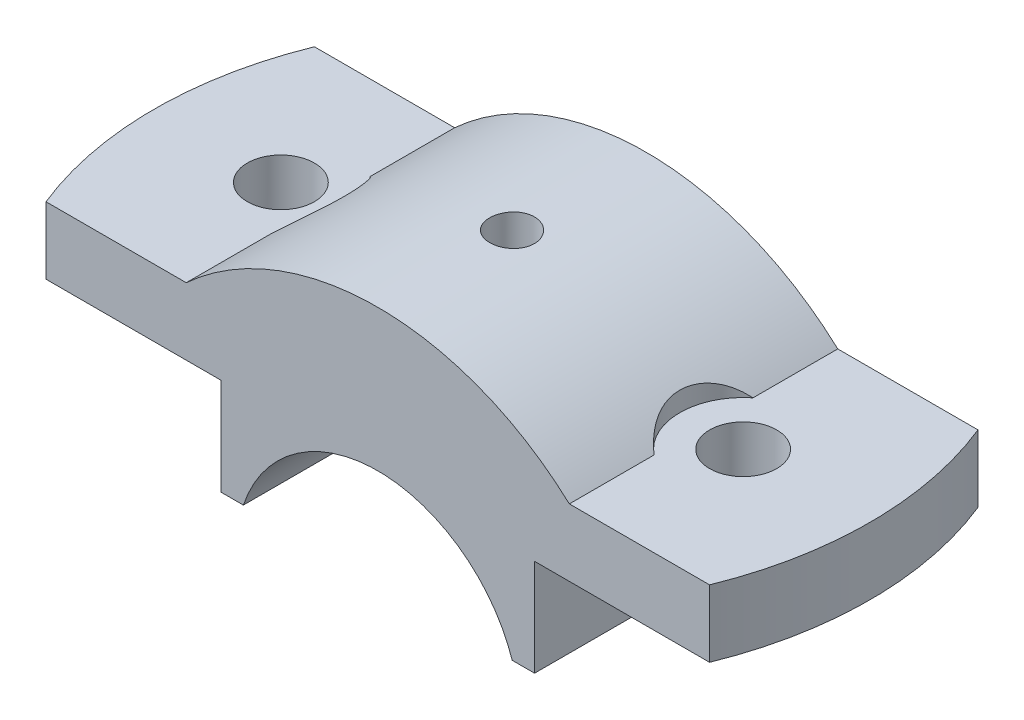
from build123d import *

# Parameters (mm, degrees)
BOSS_EXTRUDE2_DEPTH   = 18
F_6_0MM_DOWEL_HOLE4_D = 9
SKETCH16_R            = 8.5
CUT_EXTRUDE1_DEPTH    = 10
SKETCH17_R            = 8.5
CUT_EXTRUDE2_DEPTH    = 45
CUT_EXTRUDE3_DEPTH    = 23.0000001


with BuildPart() as part:
    # Sketch1 → Boss-Extrude2 (new body, symmetric)
    with BuildSketch(Plane.XY):
        with BuildLine():
            Line((18.027756377, 6), (21.027756377, 6))
            Line((21.027756377, 6), (21.027756377, 19))
            Line((21.027756377, 19), (50, 19))
            Line((50, 19), (50, 28))
            Line((50, 28), (25.690465157, 28))
            ThreePointArc((25.690465157, 28), (0, 38), (-25.690465157, 28))
            Line((-25.690465157, 28), (-50, 28))
            Line((-50, 28), (-50, 19))
            Line((-50, 19), (-21.027756377, 19))
            Line((-21.027756377, 19), (-21.027756377, 6))
            Line((-21.027756377, 6), (-18.027756377, 6))
            ThreePointArc((-18.027756377, 6), (0, 19), (18.027756377, 6))
        make_face()
    extrude(amount=BOSS_EXTRUDE2_DEPTH, both=True)

    # Ø6.0mm Dowel Hole4 (through all)
    with Locations(Plane(origin=(0, 28, 0), x_dir=(1, 0, 0), z_dir=(0, 1, 0))):
        with Locations((-31, 0)):
            f_6_0mm_dowel_hole4 = Hole(F_6_0MM_DOWEL_HOLE4_D / 2)

    # Mirror1: Ø6.0mm Dowel Hole4 across plane
    add(f_6_0mm_dowel_hole4.mirror(Plane(origin=(0, 0, 0), x_dir=(0, 0, 1), z_dir=(1, 0, 0))), mode=Mode.SUBTRACT)

    # Sketch16 → Cut-Extrude1 (cut)
    with BuildSketch(Plane(origin=(0, 38, 0), x_dir=(1, 0, 0), z_dir=(0, 1, 0))):
        with Locations((-31, 0)):
            Circle(SKETCH16_R)
    extrude(amount=-CUT_EXTRUDE1_DEPTH, mode=Mode.SUBTRACT)

    # Sketch17 → Cut-Extrude2 (cut)
    with BuildSketch(Plane(origin=(0, 28, 0), x_dir=(1, 0, 0), z_dir=(0, 1, 0))):
        with Locations((31, 0)):
            Circle(SKETCH17_R)
    extrude(amount=CUT_EXTRUDE2_DEPTH, mode=Mode.SUBTRACT)

    # Sketch18 → CBORE for M5 Hex Head Bolt1 (revolve, cut)
    with BuildSketch(Plane(origin=(0, 38, 0), x_dir=(0, 0, 1), z_dir=(1, 0, 0))):
        Polygon((0, 0), (0, 32), (2.5, 32), (2.5, 13.495), (2.995, 13), (3, 13), (3, 0), align=None)
    revolve(axis=Axis((0, 44.35, 0), (0, -1, 0)), mode=Mode.SUBTRACT)

    # Sketch19 → Cut-Extrude3 (cut, through all)
    with BuildSketch(Plane(origin=(0, 28, 0), x_dir=(1, 0, 0), z_dir=(0, 1, 0))):
        with BuildLine():
            Line((-50, 18), (-44.497190923, 18))
            ThreePointArc((-44.497190923, 18), (-48, 0), (-44.497190923, -18))
            Line((-44.497190923, -18), (-50, -18))
            Line((-50, -18), (-50, 18))
        make_face()
    cut_extrude3 = extrude(amount=-CUT_EXTRUDE3_DEPTH, mode=Mode.SUBTRACT)

    # Mirror2: Cut-Extrude3 across plane
    add(cut_extrude3.mirror(Plane(origin=(0, 0, 0), x_dir=(0, 0, 1), z_dir=(1, 0, 0))), mode=Mode.SUBTRACT)


solid = part.part
